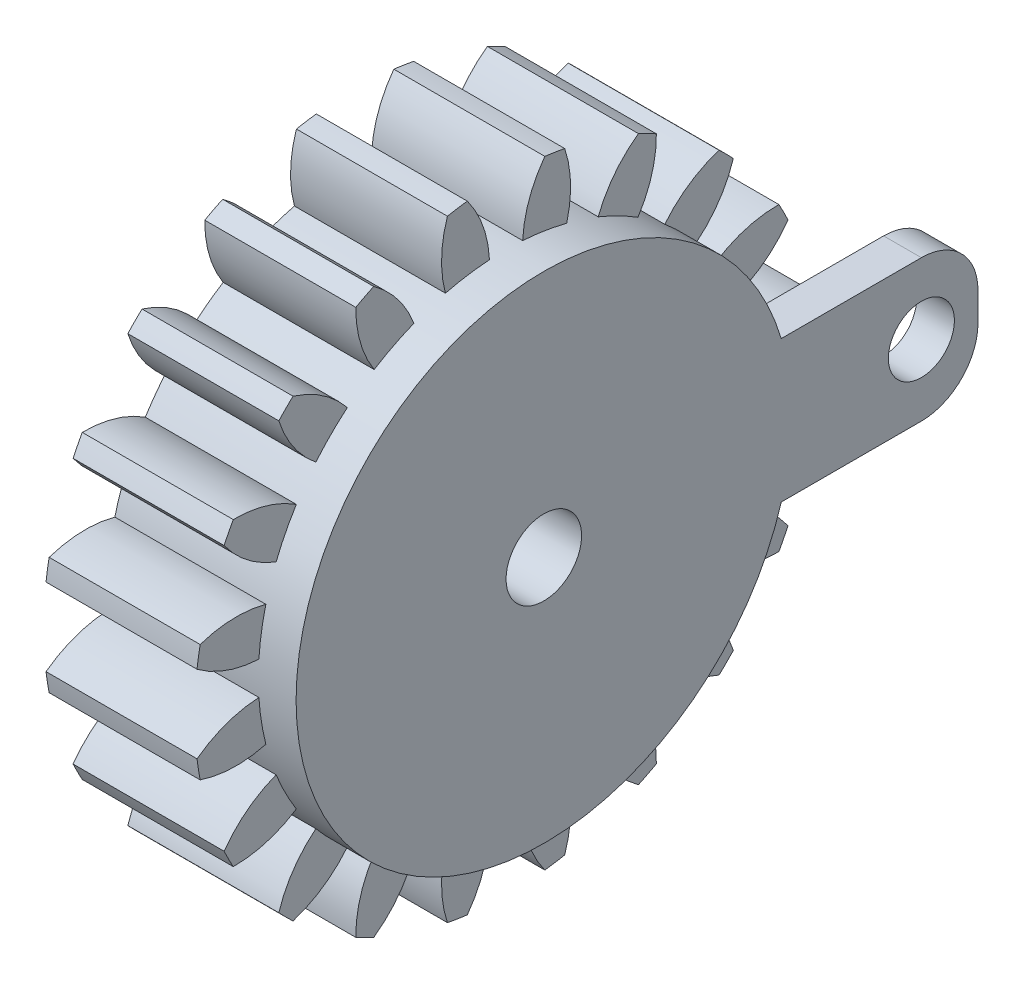
from build123d import *

# Parameters (mm, degrees)
BASPROSKE_W         = 8
BASPROSKE_H         = 16.5
TOOTHCUT_DEPTH      = 25.667792767
TEETHCUTS_COUNT     = 20
TEETHCUTS_ANGLE     = 342
BORSKE_R            = 2
BORE_DEPTH          = 50.0000508
SKETCH1_R           = 1.75
BOSS_EXTRUDE1_DEPTH = 2
BOSS_EXTRUDE2_DEPTH = 2
SKETCH3_R           = 2
CUT_EXTRUDE1_DEPTH  = 15
FILLET1_R           = 3


with BuildPart() as part:
    # BasProSke → Base-Revolve (revolve)
    with BuildSketch(Plane(origin=(0, 0, 0), x_dir=(1, 0, 0), z_dir=(0, 1, 0)), mode=Mode.PRIVATE) as base_revolve_sk:
        with Locations((4, 8.25)):
            Rectangle(BASPROSKE_W, BASPROSKE_H)
    revolve(base_revolve_sk.sketch.rotate(Axis((-10, 0, 0), (1, 0, 0)), 180), axis=Axis((-10, 0, 0), (1, 0, 0)))

    # TooCutSke → ToothCut (cut, through all)
    with BuildSketch(Plane(origin=(0, 0, 0), x_dir=(0, 0, -1), z_dir=(1, 0, 0))):
        with BuildLine():
            ThreePointArc((0.877929023, 13.094602576), (0, 13.124), (-0.877929023, 13.094602576))
            ThreePointArc((-0.877929023, 13.094602576), (-1.227785764, 14.834041313), (-2.071065599, 16.395106966))
            ThreePointArc((-2.071065599, 16.395106966), (0, 16.5254), (2.071065599, 16.395106966))
            ThreePointArc((2.071065599, 16.395106966), (1.227785764, 14.834041313), (0.877929023, 13.094602576))
        make_face()
    toothcut = extrude(amount=TOOTHCUT_DEPTH, mode=Mode.SUBTRACT)

    # TeethCuts: ToothCut ×20 about axis
    teethcuts_axis = Axis((-10, 0, 0), (1, 0, 0))
    for i in range(1, TEETHCUTS_COUNT):
        add(toothcut.rotate(teethcuts_axis, i * TEETHCUTS_ANGLE / (TEETHCUTS_COUNT - 1)), mode=Mode.SUBTRACT)

    # BorSke → Bore (cut, symmetric)
    with BuildSketch(Plane(origin=(0, 0, 0), x_dir=(0, 0, -1), z_dir=(1, 0, 0))):
        with Locations(Location((0, 0, 0), (0, 0, 180))):
            Circle(BORSKE_R)
    extrude(amount=BORE_DEPTH, both=True, mode=Mode.SUBTRACT)

    # Sketch1 → Boss-Extrude1 (add)
    with BuildSketch(Plane(origin=(8, 0, 0), x_dir=(0, 0, -1), z_dir=(1, 0, 0))):
        Polygon((0, 0), (0, 3.75), (20, 3.75), (23, 3.75), (23, -3.75), (0, -3.75), align=None)
        with Locations((20, 0)):
            Circle(SKETCH1_R, mode=Mode.SUBTRACT)
    extrude(amount=BOSS_EXTRUDE1_DEPTH)

    # Sketch2 → Boss-Extrude2 (add)
    with BuildSketch(Plane(origin=(8, 0, 0), x_dir=(0, 0, -1), z_dir=(1, 0, 0))):
        with BuildLine():
            Line((0, 3.75), (12.576838872, 3.75))
            ThreePointArc((12.576838872, 3.75), (-13.124, 0), (12.576838872, -3.75))
            Line((12.576838872, -3.75), (0, -3.75))
            Line((0, -3.75), (0, 3.75))
        make_face()
    extrude(amount=BOSS_EXTRUDE2_DEPTH)

    # Sketch3 → Cut-Extrude1 (cut)
    with BuildSketch(Plane.ZY):
        Circle(SKETCH3_R)
    extrude(amount=-CUT_EXTRUDE1_DEPTH, mode=Mode.SUBTRACT)

    # Fillet1
    fillet1_edges = [part.edges().sort_by_distance(p)[0] for p in [
        (9, -3.75, -23),
        (9, 3.75, -23),
    ]]
    fillet(fillet1_edges, radius=FILLET1_R)


solid = part.part
